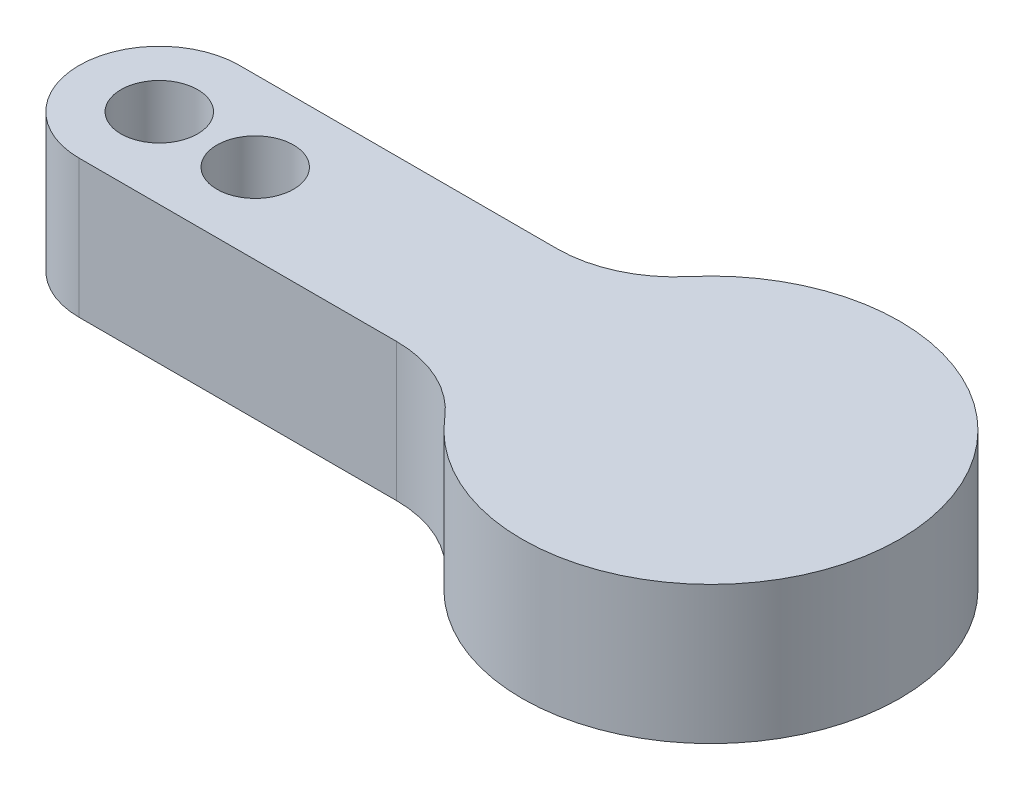
from build123d import *

# Parameters (mm, degrees)
SKETCH1_R           = 1.625
BOSS_EXTRUDE1_DEPTH = 5.842


with BuildPart() as part:
    # Sketch1 → Boss-Extrude1 (new body)
    with BuildSketch(Plane(origin=(0, 0, 0), x_dir=(1, 0, 0), z_dir=(0, 1, 0))):
        with BuildLine():
            Line((-9.921693404, 3.4), (-23.368, 3.4))
            ThreePointArc((-23.368, 3.4), (-26.768, 0), (-23.368, -3.4))
            Line((-23.368, -3.4), (-9.921693404, -3.4))
            ThreePointArc((-9.921693404, -3.4), (-7.818582155, -3.863820652), (-6.105657479, -5.169230769))
            ThreePointArc((-6.105657479, -5.169230769), (8, 0), (-6.105657479, 5.169230769))
            ThreePointArc((-6.105657479, 5.169230769), (-7.818582155, 3.863820652), (-9.921693404, 3.4))
        make_face()
        with Locations((-23.368, 0)):
            Circle(SKETCH1_R, mode=Mode.SUBTRACT)
        with Locations((-19.304, 0)):
            Circle(SKETCH1_R, mode=Mode.SUBTRACT)
    extrude(amount=BOSS_EXTRUDE1_DEPTH)


solid = part.part
